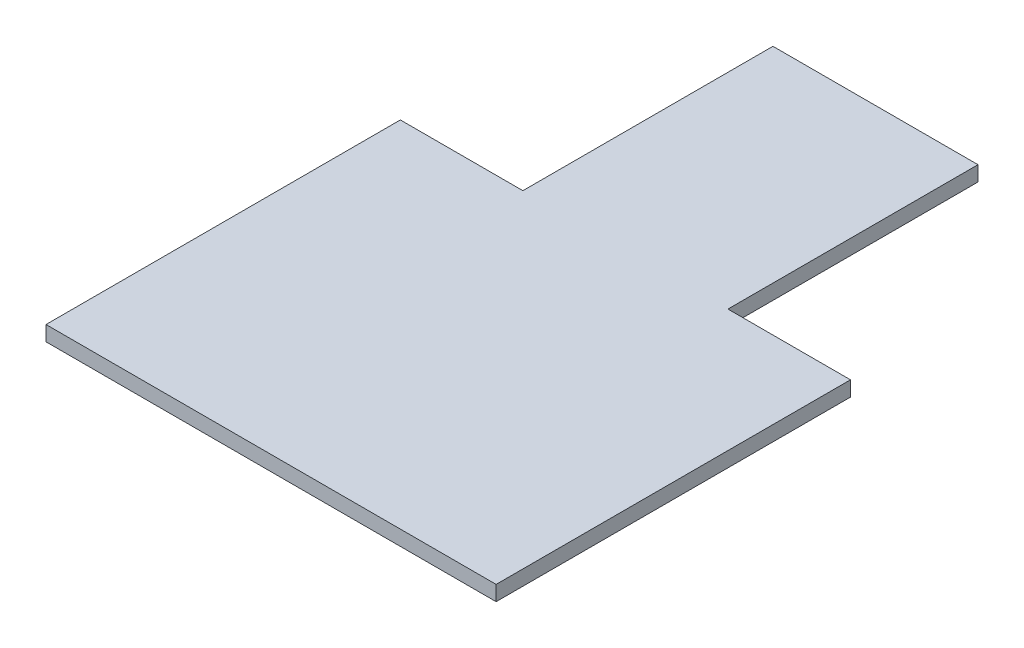
from build123d import *

# Parameters (mm, degrees)
BOSS_EXTRUDE1_DEPTH = 3


with BuildPart() as part:
    # Sketch1 → Boss-Extrude1 (new body)
    with BuildSketch(Plane(origin=(0, 0, 0), x_dir=(1, 0, 0), z_dir=(0, 1, 0))):
        Polygon((20.5, 60.804597701), (-20.5, 60.804597701), (-20.5, 10.804597701), (-45, 10.804597701), (-45, -60.045977011), (45, -60.045977011), (45, 10.804597701), (20.5, 10.804597701), align=None)
    extrude(amount=BOSS_EXTRUDE1_DEPTH)


solid = part.part
